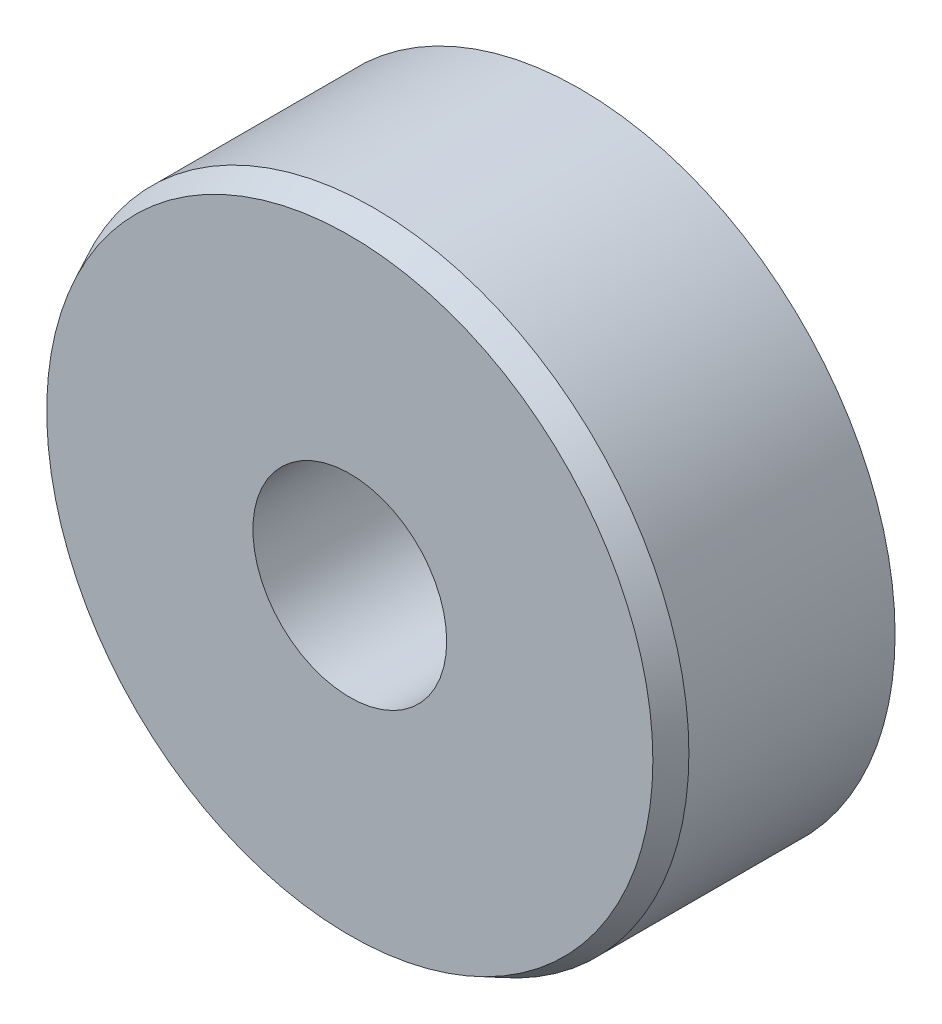
from build123d import *

# Parameters (mm, degrees)
SKETCH1_R             = 6.5
SKETCH1_R_2           = 2
BOSS_EXTRUDE1_DEPTH   = 5
CHAMFER1_SIZE         = 0.5
CHAMFER1_SIZE2        = 0.243866294
CHAMFER1_PART_2_SIZE  = 0.5
CHAMFER1_PART_2_SIZE2 = 0.243866294


with BuildPart() as part:
    # Sketch1 → Boss-Extrude1 (new body)
    with BuildSketch(Plane.XY):
        Circle(SKETCH1_R)
        Circle(SKETCH1_R_2, mode=Mode.SUBTRACT)
    extrude(amount=BOSS_EXTRUDE1_DEPTH)

    # Chamfer1
    chamfer1_edges = [part.edges().sort_by_distance(p)[0] for p in [
        (-6.5, 0, 0),
    ]]
    chamfer1_side = [part.faces().sort_by_distance(p)[0] for p in [
        (-6.316152237, 0, 0),
    ]]
    chamfer(chamfer1_edges, length=CHAMFER1_SIZE, length2=CHAMFER1_SIZE2, reference=chamfer1_side[0])

    # Chamfer1 part 2
    chamfer1_part_2_edges = [part.edges().sort_by_distance(p)[0] for p in [
        (-6.5, 0, 5),
    ]]
    chamfer1_part_2_side = [part.faces().sort_by_distance(p)[0] for p in [
        (-6.5, 0, 2.5),
    ]]
    chamfer(chamfer1_part_2_edges, length=CHAMFER1_PART_2_SIZE, length2=CHAMFER1_PART_2_SIZE2, reference=chamfer1_part_2_side[0])


solid = part.part
